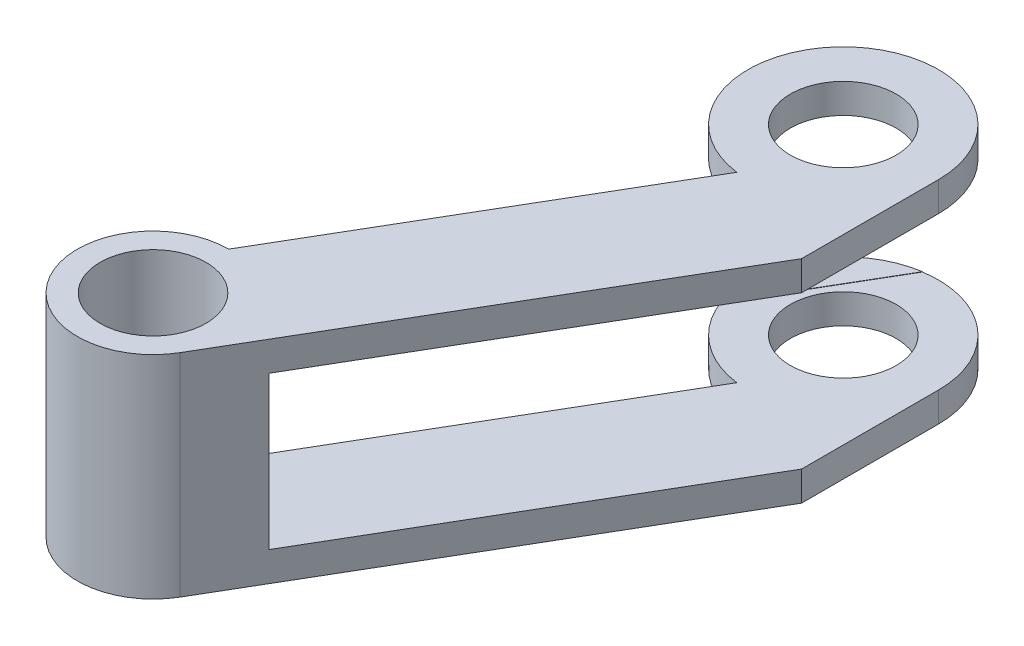
from build123d import *

# Parameters (mm, degrees)
BOSS_EXTRUDE1_DEPTH     = 10
SKETCH2_W               = 18
SKETCH2_H               = 7.18
CUT_EXTRUDE1_DEPTH      = 4.5
CUT_EXTRUDE1_DEPTH_BACK = 10
SKETCH3_R               = 2.5
CUT_EXTRUDE2_DEPTH      = 11
SKETCH4_R               = 2.5
CUT_EXTRUDE3_DEPTH      = 11
SKETCH5_W               = 40.184042348
SKETCH5_H               = 7.210208874
CUT_EXTRUDE4_DEPTH      = 10


with BuildPart() as part:
    # Sketch1 → Boss-Extrude1 (new body)
    with BuildSketch(Plane(origin=(0, 0, 0), x_dir=(1, 0, 0), z_dir=(0, 1, 0))):
        with BuildLine():
            Line((4.5, 0), (4.5, -6.46875))
            Line((4.5, -6.46875), (-6.330925138, -24.986801467))
            ThreePointArc((-6.330925138, -24.986801467), (-12.518133398, -24.960664715), (-9.416959682, -19.606698823))
            Line((-9.416959682, -19.606698823), (-0.560766754, -4.464923364))
            ThreePointArc((-0.560766754, -4.464923364), (-2.977125258, 3.374422202), (4.5, 0))
        make_face()
    extrude(amount=BOSS_EXTRUDE1_DEPTH)

    # Sketch2 → Cut-Extrude1 (cut, two sides)
    with BuildSketch(Plane.XY) as cut_extrude1_sk:
        with Locations((4.5, 5)):
            Rectangle(SKETCH2_W, SKETCH2_H)
    extrude(amount=CUT_EXTRUDE1_DEPTH, mode=Mode.SUBTRACT)
    extrude(cut_extrude1_sk.sketch, amount=-CUT_EXTRUDE1_DEPTH_BACK, mode=Mode.SUBTRACT)

    # Sketch3 → Cut-Extrude2 (cut, through all)
    with BuildSketch(Plane(origin=(0, 10, 0), x_dir=(1, 0, 0), z_dir=(0, 1, 0))):
        Circle(SKETCH3_R)
    extrude(amount=-CUT_EXTRUDE2_DEPTH, mode=Mode.SUBTRACT)

    # Sketch4 → Cut-Extrude3 (cut, through all)
    with BuildSketch(Plane(origin=(0, 10, 0), x_dir=(1, 0, 0), z_dir=(0, 1, 0))):
        with Locations((-9.416959682, -23.181827052)):
            Circle(SKETCH4_R)
    extrude(amount=-CUT_EXTRUDE3_DEPTH, mode=Mode.SUBTRACT)

    # Sketch5 → Cut-Extrude4 (cut)
    with BuildSketch(Plane(origin=(6.172069089, 0, 3.609948831), x_dir=(0.50486984, 0, -0.863195485), z_dir=(0.863195485, 0, 0.50486984))):
        with Locations((-1.612465403, 5)):
            Rectangle(SKETCH5_W, SKETCH5_H)
    extrude(amount=-CUT_EXTRUDE4_DEPTH, mode=Mode.SUBTRACT)


solid = part.part
